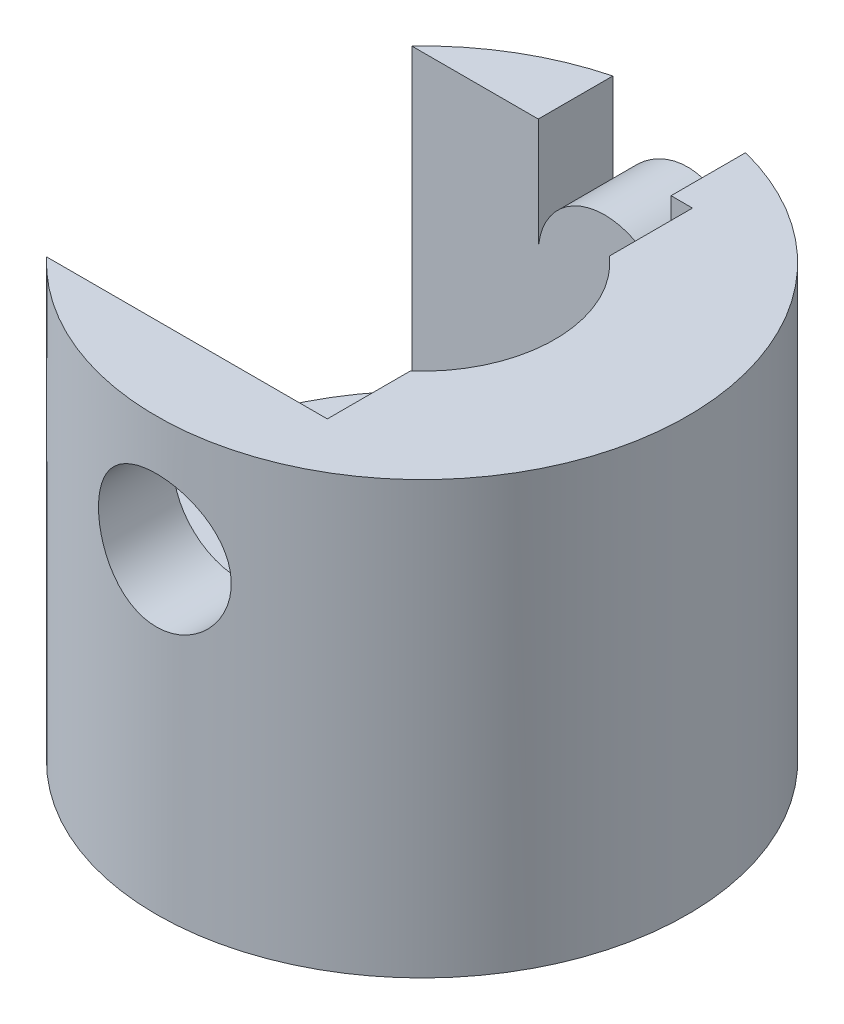
from build123d import *

# Parameters (mm, degrees)
SKETCH_1_R               = 80
EXTRUDE_1_DEPTH          = 130
SKETCH_2_R               = 40
CUT_EXTRUDE_1_DEPTH      = 40
CUT_EXTRUDE_3_DEPTH      = 90
SKETCH_4_R               = 20
CUT_EXTRUDE_4_DEPTH      = 173.336879396
CUT_EXTRUDE_4_DEPTH_BACK = 173.336879396
CUT_EXTRUDE_8_REACH      = 174.337
CUT_EXTRUDE_8_END_RADIUS = 20
EXTRUDE_5_REACH          = 205.777
EXTRUDE_5_END_RADIUS     = 80
SKETCH_8_R               = 20


with BuildPart() as part:
    # 草图1 → 凸台-拉伸1 (new body)
    with BuildSketch(Plane(origin=(0, 0, 0), x_dir=(1, 0, 0), z_dir=(0, 1, 0))):
        with Locations(Location((0, 0, 0), (0, 0, 270))):
            Circle(SKETCH_1_R)
    extrude(amount=EXTRUDE_1_DEPTH)

    # 草图2 → 切除-拉伸1 (cut)
    with BuildSketch(Plane.XZ):
        with Locations(Location((0, 0, 0), (0, 0, 270))):
            Circle(SKETCH_2_R)
    extrude(amount=-CUT_EXTRUDE_1_DEPTH, mode=Mode.SUBTRACT)

    # 草图3 → 切除-拉伸3 (cut)
    with BuildSketch(Plane.XZ.offset(-40)):
        with BuildLine():
            Line((-58.094750193, 55), (26.457513111, 55))
            Line((26.457513111, 55), (26.457513111, 30))
            ThreePointArc((26.457513111, 30), (40, 0), (26.457513111, -30))
            Line((26.457513111, -30), (26.457513111, -55))
            Line((26.457513111, -55), (-58.094750193, -55))
            ThreePointArc((-58.094750193, -55), (-80, 0), (-58.094750193, 55))
        make_face()
    extrude(amount=-CUT_EXTRUDE_3_DEPTH, mode=Mode.SUBTRACT)

    # 草图4 → 切除-拉伸4 (cut, two sides)
    with BuildSketch(Plane.XY) as cut_extrude_4_sk:
        with Locations(Location((0, 95, 0), (0, 0, 180))):
            Circle(SKETCH_4_R)
    extrude(amount=CUT_EXTRUDE_4_DEPTH, mode=Mode.SUBTRACT)
    extrude(cut_extrude_4_sk.sketch, amount=-CUT_EXTRUDE_4_DEPTH_BACK, mode=Mode.SUBTRACT)

    # 切除-拉伸8: up to this cylinder (the profile starts outside it)
    cut_extrude_8_end = Plane(origin=(0, 95, -67.091154), z_dir=(0, 0, -1)) * Cylinder(CUT_EXTRUDE_8_END_RADIUS, 389.674, mode=Mode.PRIVATE)
    # 草图7 → 切除-拉伸8 (cut, up to the surface)
    with BuildSketch(Plane(origin=(0, 130, 0), x_dir=(1, 0, 0), z_dir=(0, 1, 0)), mode=Mode.PRIVATE) as cut_extrude_8_sk1:
        with BuildLine():
            Line((20, 55), (-20, 55))
            Line((-20, 55), (-20, 77.459666924))
            ThreePointArc((-20, 77.459666924), (0, 80), (20, 77.459666924))
            Line((20, 77.459666924), (20, 55))
        make_face()
    cut_extrude_8_tool1 = extrude(cut_extrude_8_sk1.sketch, amount=-CUT_EXTRUDE_8_REACH, mode=Mode.PRIVATE) - cut_extrude_8_end
    add(cut_extrude_8_tool1.solids().sort_by_distance((0, 130, -67.091154))[0], mode=Mode.SUBTRACT)

    # 凸台-拉伸5: up to this cylinder (the profile starts inside it)
    extrude_5_end = Plane(origin=(0, 95, 0), z_dir=(0, -1, 0)) * Cylinder(EXTRUDE_5_END_RADIUS, 572.554, mode=Mode.PRIVATE)
    # 草图8 → 凸台-拉伸5 (add, up to the surface)
    with BuildSketch(Plane.XY.offset(-55), mode=Mode.PRIVATE) as extrude_5_sk1:
        with Locations(Location((0, 95, 0), (0, 0, 270))):
            Circle(SKETCH_8_R)
    extrude_5_tool1 = extrude(extrude_5_sk1.sketch, amount=-EXTRUDE_5_REACH, mode=Mode.PRIVATE) & extrude_5_end
    add(extrude_5_tool1.solids().sort_by_distance((0, 95, -55))[0])


solid = part.part
